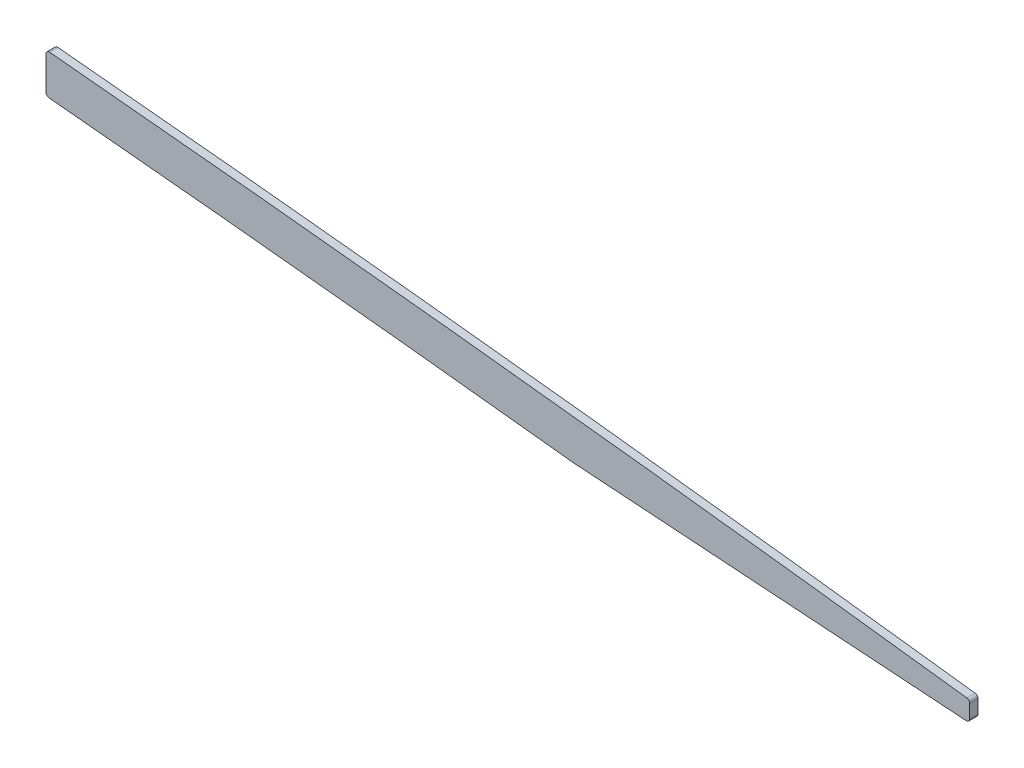
from build123d import *

# Parameters (mm, degrees)
BOSS_EXTRUDE1_DEPTH = 1.5875
FILLET1_R           = 1.27


with BuildPart() as part:
    # Sketch2 → Boss-Extrude1 (new body, symmetric)
    with BuildSketch(Plane.XY):
        with BuildLine():
            add(Edge.make_bspline(
                [(2311.4, 135.829939705), (2328.342945407, 134.244574235), (2345.393069943, 132.62356173), (2362.559217098, 130.963943098), (2433.544115673, 123.962494813), (2504.529014249, 116.360848787), (2558.570986897, 110.161821317), (2612.080990815, 103.726427275), (2665.4125, 96.996301665)],
                knots=[225.60075304, 225.60075304, 225.60075304, 225.60075304, 225.60075304, 225.60075304, 233.9431167, 233.9431167, 233.9431167, 260.757015076, 260.757015076, 260.757015076, 260.757015076, 260.757015076, 260.757015076], degree=5))
            Line((2311.4, 135.829939705), (2311.4, 120.523308441))
            add(Edge.make_bspline(
                [(2311.4, 120.523308441), (2313.552310931, 120.321692016), (2325.557433475, 119.19433883), (2347.551509172, 117.100365283), (2377.159899727, 114.21011853), (2406.469653851, 111.26896801), (2435.81832606, 108.240091266), (2469.024707522, 104.715289085), (2494.87246064, 101.880060077), (2510.934244559, 100.080155034), (2513.371052459, 99.806213346)],
                knots=[225.740445061, 225.740445061, 225.740445061, 225.740445061, 226.376989508, 229.287698684, 232.19840786, 235.109117037, 238.019826213, 240.930535389, 244.998118743, 245.725796037, 245.725796037, 245.725796037, 245.725796037], degree=3))
            Line((2513.371052459, 99.806213346), (2665.4125, 89.358331764))
            Line((2665.4125, 89.358331764), (2665.4125, 96.996301665))
        make_face()
    extrude(amount=BOSS_EXTRUDE1_DEPTH, both=True)

    # Fillet1
    fillet1_edges = [part.edges().sort_by_distance(p)[0] for p in [
        (2311.4, 120.523308441, -0.79375),
        (2311.4, 135.829939705, 0.79375),
        (2665.4125, 96.996301665, -0.79375),
        (2665.4125, 89.358331764, 0),
    ]]
    fillet(fillet1_edges, radius=FILLET1_R)


solid = part.part
